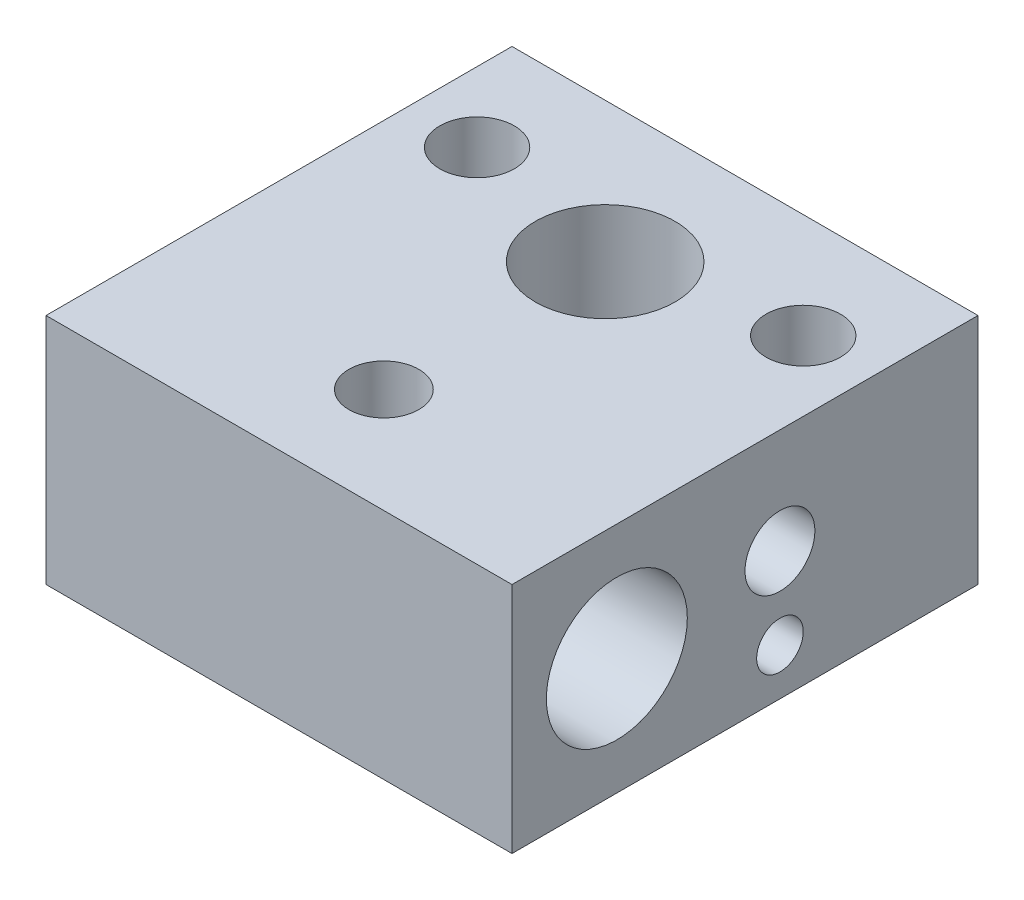
from build123d import *

# Parameters (mm, degrees)
SKETCH1_W           = 20
SKETCH1_H           = 20
BOSS_EXTRUDE1_DEPTH = 10
SKETCH2_R           = 3
CUT_EXTRUDE1_DEPTH  = 18.320508076
SKETCH3_R           = 1.6
CUT_EXTRUDE2_DEPTH  = 18.320508076
CHAMFER1_SIZE       = 1
CHAMFER2_SIZE       = 1
SKETCH5_R           = 3.025
SKETCH5_R_2         = 1
SKETCH5_R_3         = 1.5
CUT_EXTRUDE3_DEPTH  = 25.494897428
SKETCH2_3_R         = 1.5
CUT_EXTRUDE4_DEPTH  = 4


with BuildPart() as part:
    # Sketch1 → Boss-Extrude1 (new body)
    with BuildSketch(Plane(origin=(0, 0, 0), x_dir=(1, 0, 0), z_dir=(0, 1, 0))):
        Rectangle(SKETCH1_W, SKETCH1_H)
    extrude(amount=-BOSS_EXTRUDE1_DEPTH)

    # Sketch2 → Cut-Extrude1 (cut, through all)
    with BuildSketch(Plane(origin=(0, 0, 0), x_dir=(1, 0, 0), z_dir=(0, 1, 0))):
        with Locations((0, 4)):
            Circle(SKETCH2_R)
    extrude(amount=-CUT_EXTRUDE1_DEPTH, mode=Mode.SUBTRACT)

    # Sketch3 → Cut-Extrude2 (cut, through all)
    with BuildSketch(Plane(origin=(0, 0, 0), x_dir=(1, 0, 0), z_dir=(0, 1, 0))):
        with Locations((7, 5.5)):
            Circle(SKETCH3_R)
    cut_extrude2 = extrude(amount=-CUT_EXTRUDE2_DEPTH, mode=Mode.SUBTRACT)

    # Mirror1: Cut-Extrude2 across plane
    add(cut_extrude2.mirror(Plane(origin=(0, 0, 0), x_dir=(0, 0, 1), z_dir=(1, 0, 0))), mode=Mode.SUBTRACT)

    # Chamfer1
    chamfer1_edges = [part.edges().sort_by_distance(p)[0] for p in [
        (5.4, -10, -5.5),
    ]]
    chamfer(chamfer1_edges, length=CHAMFER1_SIZE)

    # Chamfer2
    chamfer2_edges = [part.edges().sort_by_distance(p)[0] for p in [
        (-5.4, -10, -5.5),
    ]]
    chamfer(chamfer2_edges, length=CHAMFER2_SIZE)

    # Sketch5 → Cut-Extrude3 (cut, through all)
    with BuildSketch(Plane(origin=(10, 0, 0), x_dir=(0, 0, -1), z_dir=(1, 0, 0))):
        with Locations((-5.5, -5)):
            Circle(SKETCH5_R)
        with Locations((1.5, -8)):
            Circle(SKETCH5_R_2)
        with Locations((1.5, -4.5)):
            Circle(SKETCH5_R_3)
    extrude(amount=-CUT_EXTRUDE3_DEPTH, mode=Mode.SUBTRACT)

    # Sketch2_3 → Cut-Extrude4 (cut)
    with BuildSketch(Plane(origin=(0, 0, 0), x_dir=(1, 0, 0), z_dir=(0, 1, 0))):
        with Locations((0, -5.5)):
            Circle(SKETCH2_3_R)
    extrude(amount=-CUT_EXTRUDE4_DEPTH, mode=Mode.SUBTRACT)


solid = part.part
